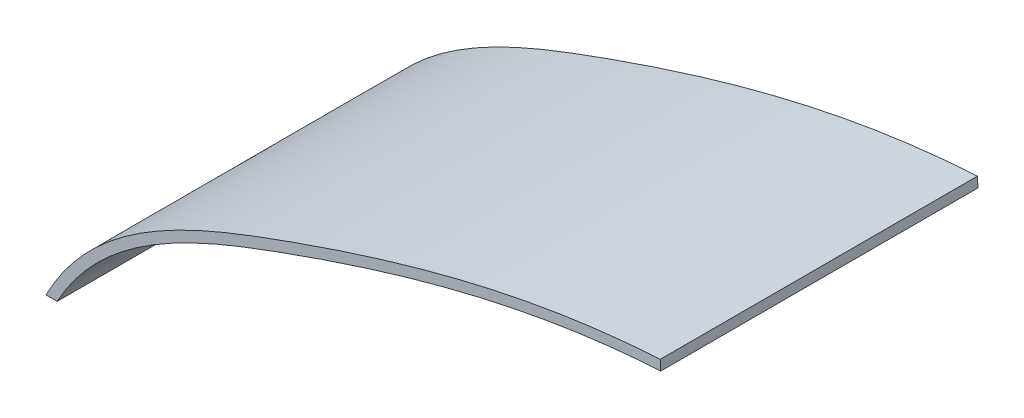
from build123d import *

# Parameters (mm, degrees)
BOSS_EXTRU_1_DEPTH = 160


with BuildPart() as part:
    # Esquisse1 → Boss.-Extru.1 (new body)
    with BuildSketch(Plane.XY):
        with BuildLine():
            add(Edge.make_bspline(
                [(-250, 70), (-226.206936908, 116.178220879), (-115.667050098, 162.54873767), (-7.405842959, 192.847275149), (59.79597522, 196.763948087)],
                knots=[0, 0, 0, 0, 0.425611974, 1, 1, 1, 1], degree=3))
            Line((-250, 70), (-244.343160897, 70))
            add(Edge.make_bspline(
                [(-244.343160897, 70), (-243.888335947, 70.836974692), (-242.538627574, 73.250803556), (-239.282280539, 78.616162041), (-234.237004509, 85.76617908), (-227.565736601, 93.635253213), (-217.899967362, 103.273091433), (-204.486092806, 113.855071148), (-186.641307768, 124.628463908), (-167.469699238, 133.881377828), (-147.418263217, 142.016984158), (-126.924965171, 149.491485063), (-106.497755999, 156.615857698), (-86.088100165, 163.272517902), (-58.840911202, 171.461327008), (-31.452907005, 178.489029557), (-3.742842968, 184.111280304), (17.244732348, 187.56362023), (34.950271462, 189.752949697), (49.253062669, 191.06025415), (56.4793158, 191.562160873), (60.086892774, 191.772418564)],
                knots=[0.007431049, 0.007431049, 0.007431049, 0.007431049, 0.015625, 0.03125, 0.0625, 0.09375, 0.125, 0.1875, 0.25, 0.3125, 0.375, 0.4375, 0.5, 0.5625, 0.625, 0.75, 0.8125, 0.875, 0.9375, 0.96875, 1, 1, 1, 1], degree=3))
            Line((60.086892774, 191.772418564), (59.79597522, 196.763948087))
        make_face()
    extrude(amount=BOSS_EXTRU_1_DEPTH)


solid = part.part
